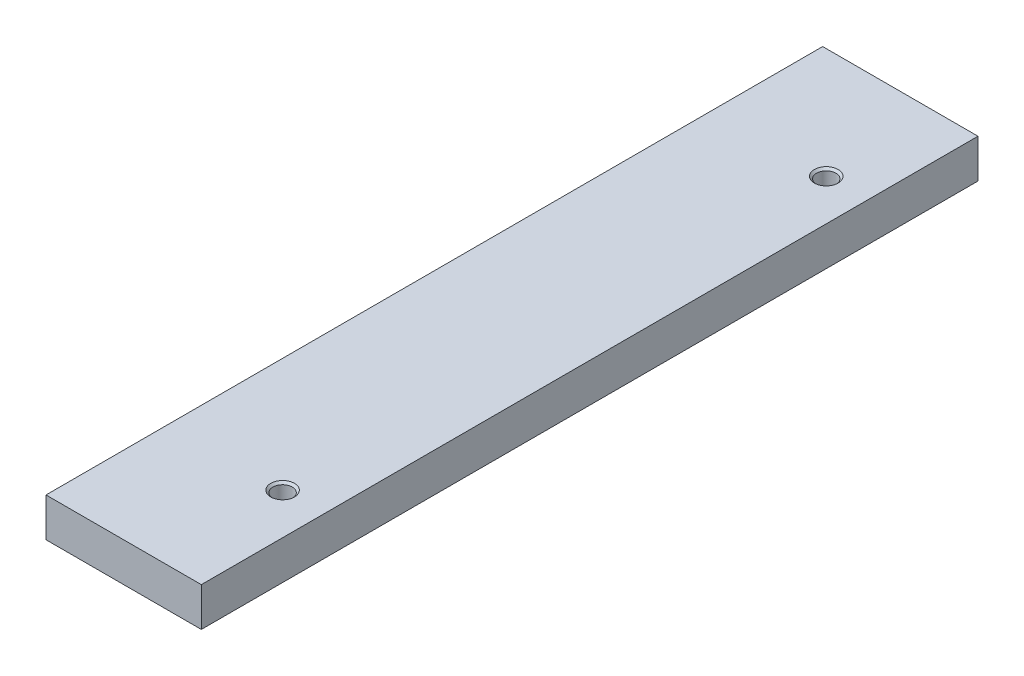
from build123d import *

# Parameters (mm, degrees)
SKETCH1_W                   = 20
SKETCH1_H                   = 5
BOSS_EXTRUDE1_DEPTH         = 100
M3_TAPPED_HOLE2_D           = 2.5
M3_TAPPED_HOLE2_CSINK_D     = 3.05
M3_TAPPED_HOLE2_CSINK_ANGLE = 90
LPATTERN1_COUNT             = 2
LPATTERN1_PITCH             = 70


with BuildPart() as part:
    # Sketch1 → Boss-Extrude1 (new body)
    with BuildSketch(Plane.XY):
        Rectangle(SKETCH1_W, SKETCH1_H)
    extrude(amount=BOSS_EXTRUDE1_DEPTH)

    # M3 Tapped Hole2 (through all)
    with Locations(Plane(origin=(0, 2.5, 0), x_dir=(1, 0, 0), z_dir=(0, 1, 0))):
        with Locations((4.698821008, -14.236441586)):
            m3_tapped_hole2 = CounterSinkHole(M3_TAPPED_HOLE2_D / 2, M3_TAPPED_HOLE2_CSINK_D / 2, counter_sink_angle=M3_TAPPED_HOLE2_CSINK_ANGLE)

    # LPattern1: M3 Tapped Hole2 ×2
    with Locations(*[(0, 0, i * LPATTERN1_PITCH) for i in range(1, LPATTERN1_COUNT)]):
        add(m3_tapped_hole2, mode=Mode.SUBTRACT)


solid = part.part
